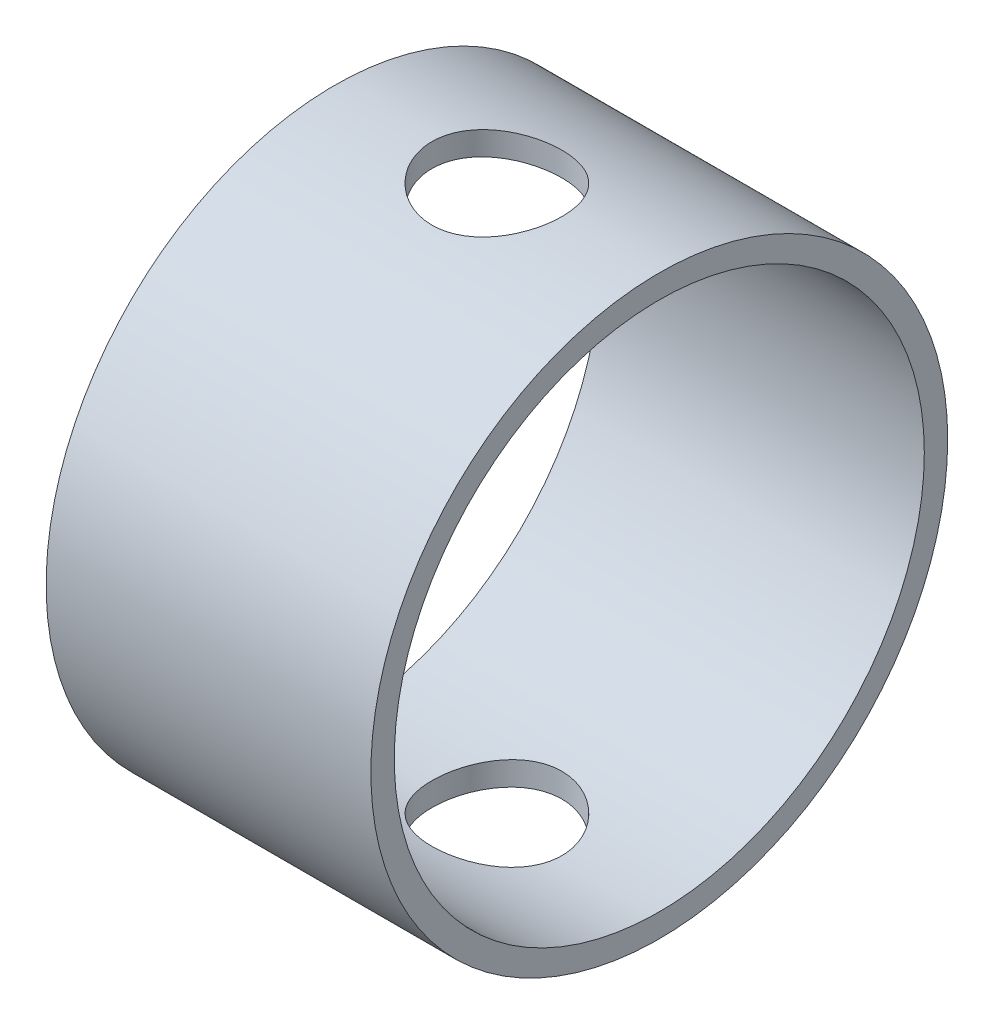
from build123d import *

# Parameters (mm, degrees)
SKETCH1_R           = 254
SKETCH1_R_2         = 233.4
BOSS_EXTRUDE1_DEPTH = 286
SKETCH2_R           = 57.25
CUT_EXTRUDE1_DEPTH  = 273


with BuildPart() as part:
    # Sketch1 → Boss-Extrude1 (new body)
    with BuildSketch(Plane(origin=(0, 0, 0), x_dir=(0, 0, -1), z_dir=(1, 0, 0))):
        Circle(SKETCH1_R)
        Circle(SKETCH1_R_2, mode=Mode.SUBTRACT)
    extrude(amount=BOSS_EXTRUDE1_DEPTH)

    # Sketch2 → Cut-Extrude1 (cut, symmetric)
    with BuildSketch(Plane(origin=(0, 0, 0), x_dir=(1, 0, 0), z_dir=(0, 1, 0))):
        with Locations((143, 0)):
            Circle(SKETCH2_R)
    extrude(amount=CUT_EXTRUDE1_DEPTH, both=True, mode=Mode.SUBTRACT)


solid = part.part
